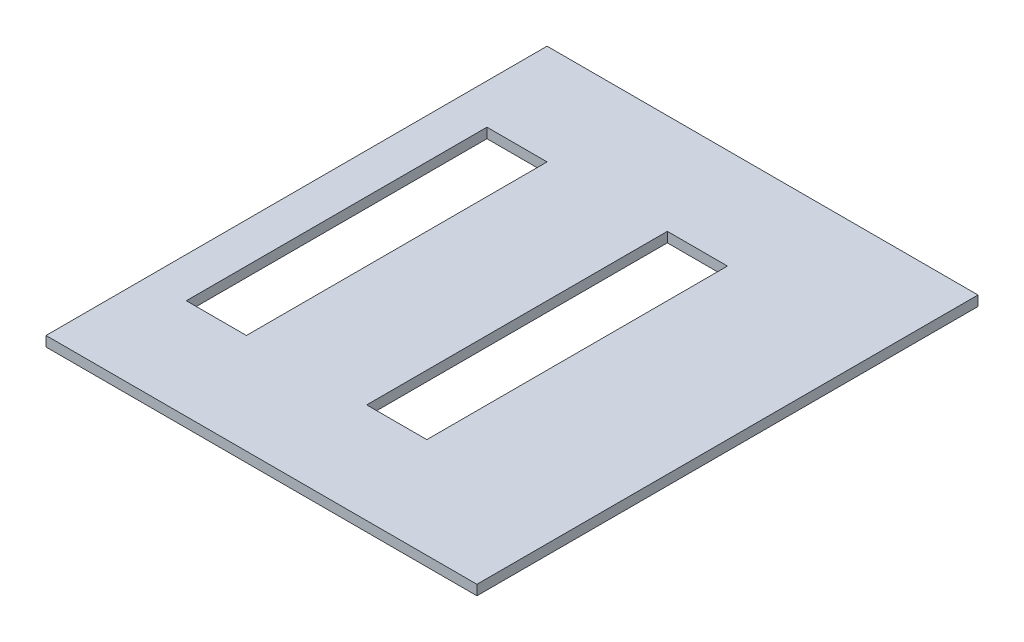
from build123d import *

# Parameters (mm, degrees)
SKETCH1_W           = 2184.4
SKETCH1_H           = 2540
BOSS_EXTRUDE1_DEPTH = 50.8
SKETCH2_W           = 304.8
SKETCH2_H           = 1524
CUT_EXTRUDE1_DEPTH  = 50.8


with BuildPart() as part:
    # Sketch1 → Boss-Extrude1 (new body)
    with BuildSketch(Plane(origin=(0, 0, 0), x_dir=(1, 0, 0), z_dir=(0, 1, 0))):
        Rectangle(SKETCH1_W, SKETCH1_H)
    extrude(amount=BOSS_EXTRUDE1_DEPTH)

    # Sketch2 → Cut-Extrude1 (cut)
    with BuildSketch(Plane(origin=(0, 50.8, 0), x_dir=(1, 0, 0), z_dir=(0, 1, 0))):
        with Locations((177.8, 0)):
            Rectangle(SKETCH2_W, SKETCH2_H)
        with Locations((-736.6, 0)):
            Rectangle(SKETCH2_W, SKETCH2_H)
    extrude(amount=-CUT_EXTRUDE1_DEPTH, mode=Mode.SUBTRACT)


solid = part.part
